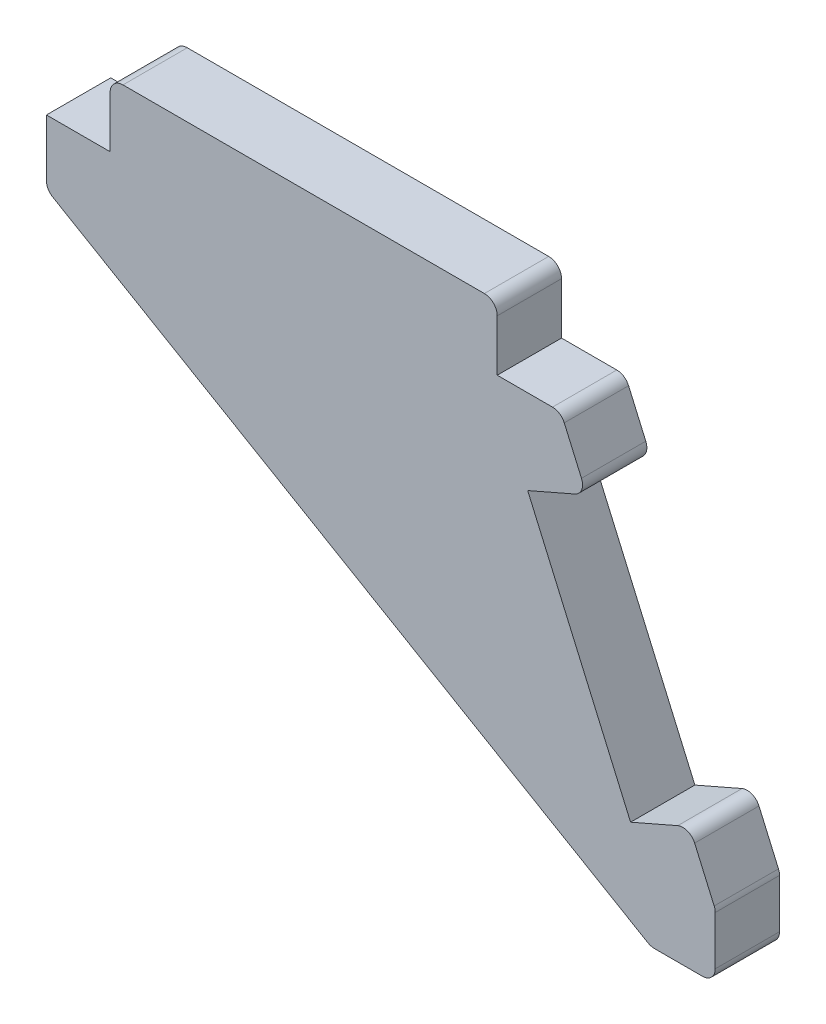
from build123d import *

# Parameters (mm, degrees)
BOSS_EXTRUDE1_DEPTH = 5
FILLET1_R           = 1


with BuildPart() as part:
    # Sketch1 → Boss-Extrude1 (new body)
    with BuildSketch(Plane.XY):
        Polygon((42, -4.582575695), (37.417424305, -6.582575695), (45.417424305, -24.912878475), (50, -22.912878475), (52, -27.49545417), (52, -32.49545417), (47, -32.49545417), (0, -5), (0, 0), (4.95, 0), (4.95, 5), (35.05, 5), (35.05, 0), (40, 0), align=None)
    extrude(amount=BOSS_EXTRUDE1_DEPTH)

    # Fillet1
    fillet1_edges = [part.edges().sort_by_distance(p)[0] for p in [
        (4.95, 5, 2.5),
        (35.05, 5, 2.5),
        (40, 0, 2.5),
        (42, -4.582575695, 2.5),
        (50, -22.912878475, 2.5),
        (52, -27.49545417, 2.5),
        (52, -32.49545417, 2.5),
        (47, -32.49545417, 2.5),
        (0, -5, 2.5),
    ]]
    fillet(fillet1_edges, radius=FILLET1_R)


solid = part.part
